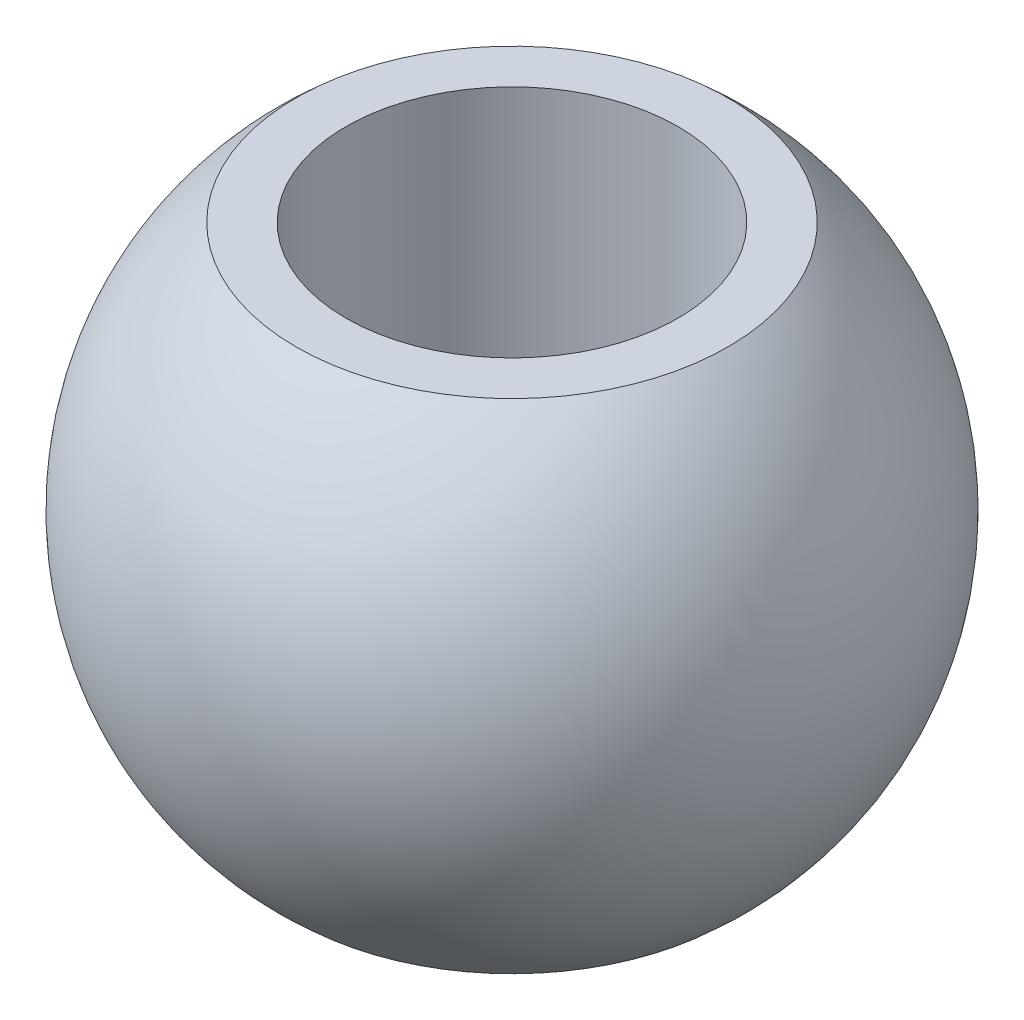
from build123d import *


with BuildPart() as part:
    # Sketch1 → Revolve1 (revolve)
    with BuildSketch(Plane.XY):
        with BuildLine():
            Line((-5.2, 12), (-4, 12))
            Line((-4, 12), (-4, 0))
            Line((-4, 0), (-5.2, 0))
            ThreePointArc((-5.2, 0), (-7.940971712, 6), (-5.2, 12))
        make_face()
    revolve(axis=Axis((0, 12, 0), (0, -1, 0)))


solid = part.part
